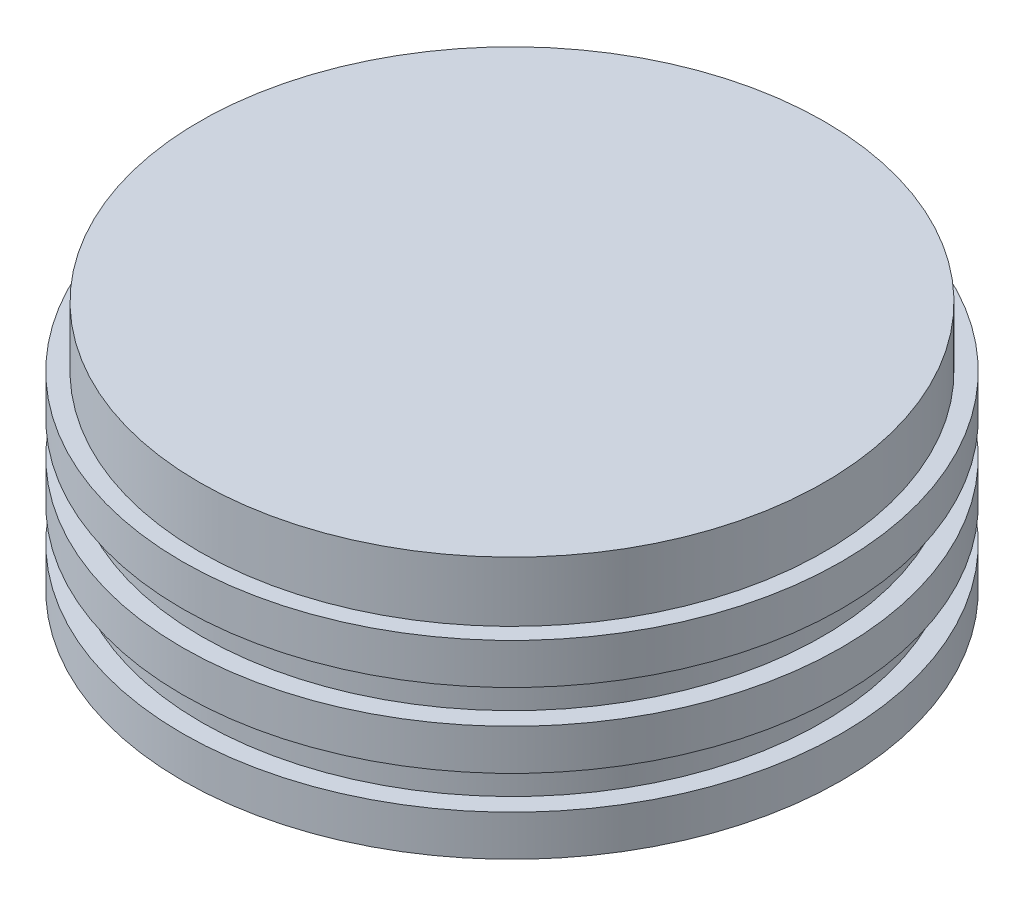
from build123d import *

# Parameters (mm, degrees)
TAP_DRILL_FOR_3_8_16_TAP1_D     = 7.9375
TAP_DRILL_FOR_3_8_16_TAP1_DEPTH = 15.875
TAP_DRILL_FOR_3_8_16_TAP1_TIP   = 2.384665582


with BuildPart() as part:
    # Sketch8 → Revolve1 (revolve)
    with BuildSketch(Plane.XY):
        Polygon((0, 0), (0, 26.416), (-33.0835, 26.416), (-33.0835, 20.066), (-34.8996, 20.066), (-34.8996, 15.748), (-32.8676, 15.748), (-32.8676, 12.192), (-34.8996, 12.192), (-34.8996, 7.874), (-32.8676, 7.874), (-32.8676, 4.318), (-34.8996, 4.318), (-34.8996, 0), align=None)
    revolve(axis=Axis((0, 0, 0), (0, 1, 0)))

    # Tap Drill for 3/8-16 Tap1
    with Locations(Plane(origin=(0, 0, 0), x_dir=(-1, 0, 0), z_dir=(0, -1, 0))):
        with Locations((0, 0)):
            Hole(TAP_DRILL_FOR_3_8_16_TAP1_D / 2, depth=TAP_DRILL_FOR_3_8_16_TAP1_DEPTH)
            with Locations((0, 0, -(TAP_DRILL_FOR_3_8_16_TAP1_DEPTH + TAP_DRILL_FOR_3_8_16_TAP1_TIP / 2))):  # 118° drill point
                Cone(0, TAP_DRILL_FOR_3_8_16_TAP1_D / 2, TAP_DRILL_FOR_3_8_16_TAP1_TIP, mode=Mode.SUBTRACT)


solid = part.part
